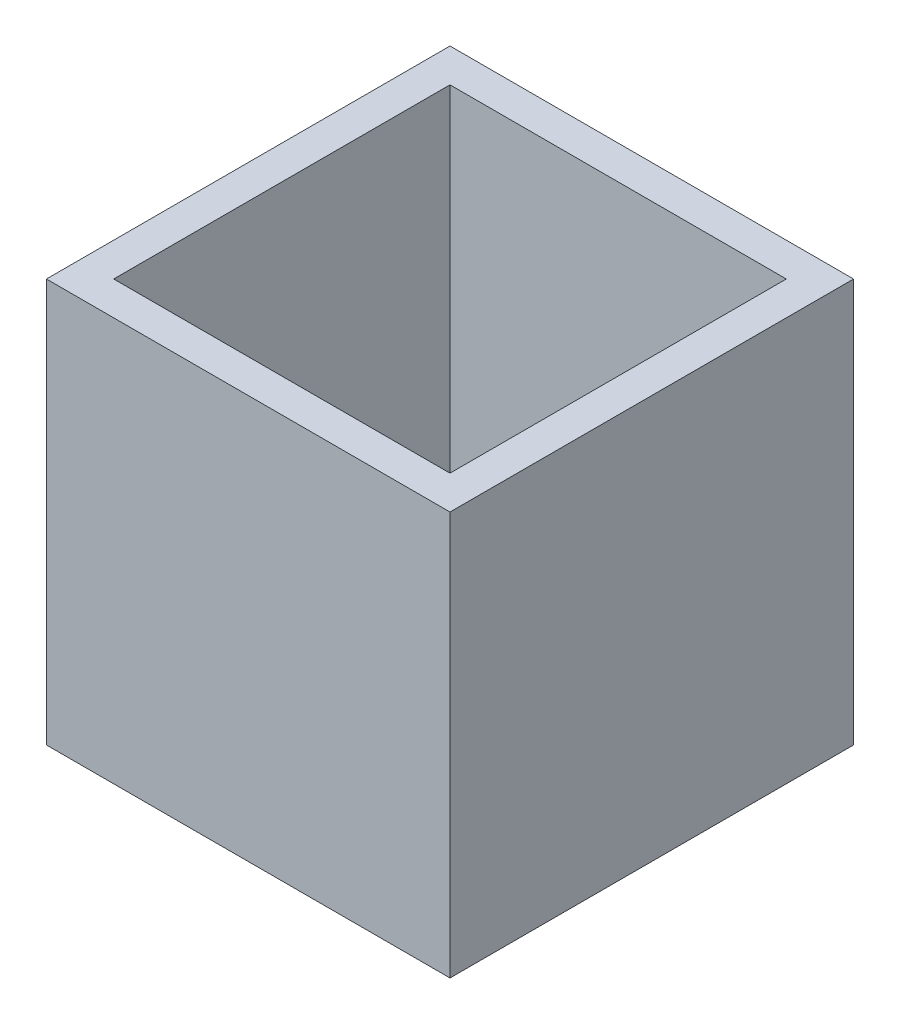
from build123d import *

# Parameters (mm, degrees)
SKETCH1_W      = 300
SKETCH1_H      = 300
EXTRUDE1_DEPTH = 300
SHELL1_T       = -25


with BuildPart() as part:
    # Sketch1 → Extrude1 (new body)
    with BuildSketch(Plane(origin=(0, 0, 0), x_dir=(1, 0, 0), z_dir=(0, 1, 0))):
        Rectangle(SKETCH1_W, SKETCH1_H)
    extrude(amount=EXTRUDE1_DEPTH)

    # Shell1
    shell1_openings = [part.faces().sort_by_distance(p)[0] for p in [
        (0, 300, 0),
    ]]
    offset(amount=SHELL1_T, openings=shell1_openings, kind=Kind.INTERSECTION)


solid = part.part
